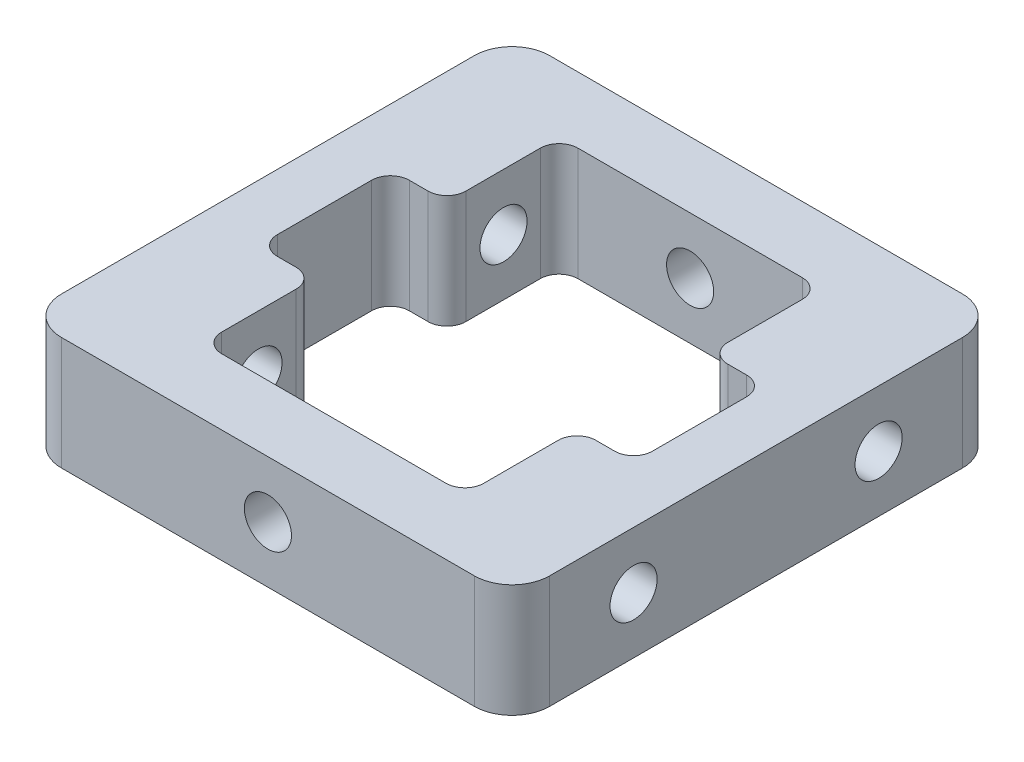
from build123d import *

# Parameters (mm, degrees)
SKETCH_1_W                   = 25.9
SKETCH_1_H                   = 25.9
EXTRUDE_1_DEPTH              = 25.9
HOLE_WIZARD_M3_1_D           = 2.5
SKETCH_7_W                   = 25.9
SKETCH_7_H                   = 9.95
CUT_EXTRUDE_4_DEPTH          = 26.9
FILLET_1_R                   = 2
CUT_EXTRUDE_5_DEPTH          = 1
CUT_EXTRUDE_5_DEPTH_BACK     = 7
FILLET_3_R                   = 1
HOLE_WIZARD_M3_2_D           = 2.5
HOLE_WIZARD_M3_2_ON_FACE_2_D = 2.5


with BuildPart() as part:
    # 草图1 → 凸台-拉伸1 (new body)
    with BuildSketch(Plane.XY):
        Rectangle(SKETCH_1_W, SKETCH_1_H)
    extrude(amount=EXTRUDE_1_DEPTH)

    # M3 螺纹孔1 (through all)
    with Locations(Plane(origin=(12.95, 0, 19.45), x_dir=(0, 0, 1), z_dir=(1, 0, 0))):
        with Locations((0, 0), (-13, 0)):
            Hole(HOLE_WIZARD_M3_1_D / 2)

    # 草图7 → 切除-拉伸4 (cut, through all)
    with BuildSketch(Plane.ZY.offset(12.95)):
        with Locations((12.95, 7.975)):
            Rectangle(SKETCH_7_W, SKETCH_7_H)
        with Locations((12.95, -7.975)):
            Rectangle(SKETCH_7_W, SKETCH_7_H)
    extrude(amount=-CUT_EXTRUDE_4_DEPTH, mode=Mode.SUBTRACT)

    # 圆角1
    fillet_1_edges = [part.edges().sort_by_distance(p)[0] for p in [
        (12.95, 0, 0),
        (-12.95, 0, 0),
        (12.95, 0, 25.9),
        (-12.95, 0, 25.9),
    ]]
    fillet(fillet_1_edges, radius=FILLET_1_R)

    # 草图8 → 切除-拉伸5 (cut, two sides)
    with BuildSketch(Plane(origin=(0, 3, 0), x_dir=(1, 0, 0), z_dir=(0, 1, 0))) as cut_extrude_5_sk:
        Polygon((-6.95, -9.45), (-9.95, -9.45), (-9.95, -16.45), (-6.95, -16.45), (-6.95, -22.4), (6.95, -22.4), (6.95, -16.45), (9.95, -16.45), (9.95, -9.45), (6.95, -9.45), (6.95, -3.5), (-6.95, -3.5), align=None)
    extrude(amount=CUT_EXTRUDE_5_DEPTH, mode=Mode.SUBTRACT)
    extrude(cut_extrude_5_sk.sketch, amount=-CUT_EXTRUDE_5_DEPTH_BACK, mode=Mode.SUBTRACT)

    # 圆角3
    fillet_3_edges = [part.edges().sort_by_distance(p)[0] for p in [
        (6.95, 0, 16.45),
        (-6.95, 0, 22.4),
        (-9.95, 0, 16.45),
        (-9.95, 0, 9.45),
        (-6.95, 0, 3.5),
        (6.95, 0, 9.45),
        (9.95, 0, 9.45),
        (9.95, 0, 16.45),
        (6.95, 0, 22.4),
        (-6.95, 0, 16.45),
        (-6.95, 0, 9.45),
        (6.95, 0, 3.5),
    ]]
    fillet(fillet_3_edges, radius=FILLET_3_R)

    # M3 螺纹孔2 (through all)
    with Locations(Plane(origin=(0, 0, 0), x_dir=(-1, 0, 0), z_dir=(0, 0, -1))):
        with Locations((0, 0)):
            Hole(HOLE_WIZARD_M3_2_D / 2)

    # M3 螺纹孔2 on face 2 (through all)
    with Locations(Plane.XY.offset(25.9)):
        with Locations((0, 0)):
            Hole(HOLE_WIZARD_M3_2_ON_FACE_2_D / 2)


solid = part.part
